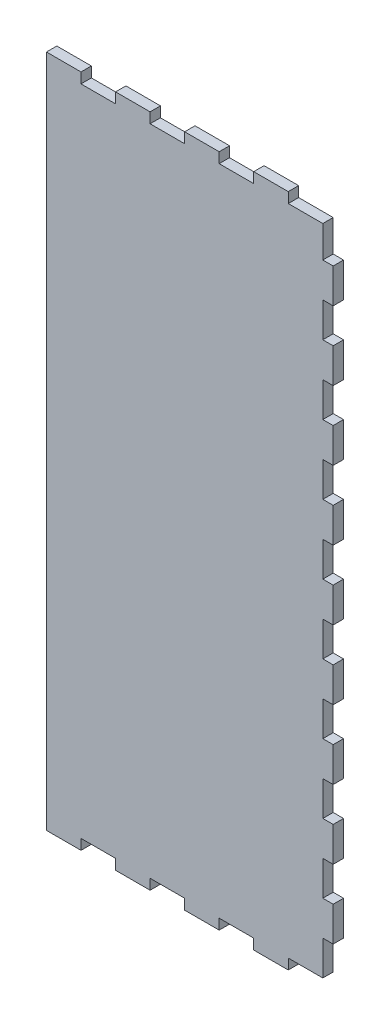
from build123d import *

# Parameters (mm, degrees)
ESQUISSE1_W                = 80
ESQUISSE1_H                = 189.15
BOSS_EXTRU_1_DEPTH         = 3
ESQUISSE3_W                = 10
ESQUISSE3_H                = 3
BOSS_EXTRU_2_DEPTH         = 3
R_P_TITION_LIN_AIRE1_COUNT = 4
R_P_TITION_LIN_AIRE1_PITCH = 20
ESQUISSE4_W                = 10
ESQUISSE4_H                = 3
BOSS_EXTRU_3_DEPTH         = 3
R_P_TITION_LIN_AIRE2_COUNT = 4
R_P_TITION_LIN_AIRE2_PITCH = 20
ESQUISSE5_W                = 3
ESQUISSE5_H                = 10
BOSS_EXTRU_4_DEPTH         = 3
R_P_TITION_LIN_AIRE3_COUNT = 9
R_P_TITION_LIN_AIRE3_PITCH = 20


with BuildPart() as part:
    # Esquisse1 → Boss.-Extru.1 (new body)
    with BuildSketch(Plane.XY):
        with Locations((40, -94.575)):
            Rectangle(ESQUISSE1_W, ESQUISSE1_H)
    extrude(amount=BOSS_EXTRU_1_DEPTH)

    # Esquisse3 → Boss.-Extru.2 (add)
    with BuildSketch(Plane(origin=(0, 0, 0), x_dir=(1, 0, 0), z_dir=(0, 1, 0))):
        with Locations((5, -1.5)):
            Rectangle(ESQUISSE3_W, ESQUISSE3_H)
    boss_extru_2 = extrude(amount=BOSS_EXTRU_2_DEPTH)

    # Répétition linéaire1: Boss.-Extru.2 ×4
    with Locations(*[(i * R_P_TITION_LIN_AIRE1_PITCH, 0, 0) for i in range(1, R_P_TITION_LIN_AIRE1_COUNT)]):
        add(boss_extru_2)

    # Esquisse4 → Boss.-Extru.3 (add)
    with BuildSketch(Plane.XZ.offset(189.15)):
        with Locations((5, 1.5)):
            Rectangle(ESQUISSE4_W, ESQUISSE4_H)
    boss_extru_3 = extrude(amount=BOSS_EXTRU_3_DEPTH)

    # Répétition linéaire2: Boss.-Extru.3 ×4
    with Locations(*[(i * R_P_TITION_LIN_AIRE2_PITCH, 0, 0) for i in range(1, R_P_TITION_LIN_AIRE2_COUNT)]):
        add(boss_extru_3)

    # Esquisse5 → Boss.-Extru.4 (add)
    with BuildSketch(Plane(origin=(80, 0, 0), x_dir=(0, 0, -1), z_dir=(1, 0, 0))):
        with Locations((-1.5, -174.15)):
            Rectangle(ESQUISSE5_W, ESQUISSE5_H)
    boss_extru_4 = extrude(amount=BOSS_EXTRU_4_DEPTH)

    # Répétition linéaire3: Boss.-Extru.4 ×9
    with Locations(*[(0, i * R_P_TITION_LIN_AIRE3_PITCH, 0) for i in range(1, R_P_TITION_LIN_AIRE3_COUNT)]):
        add(boss_extru_4)


solid = part.part
